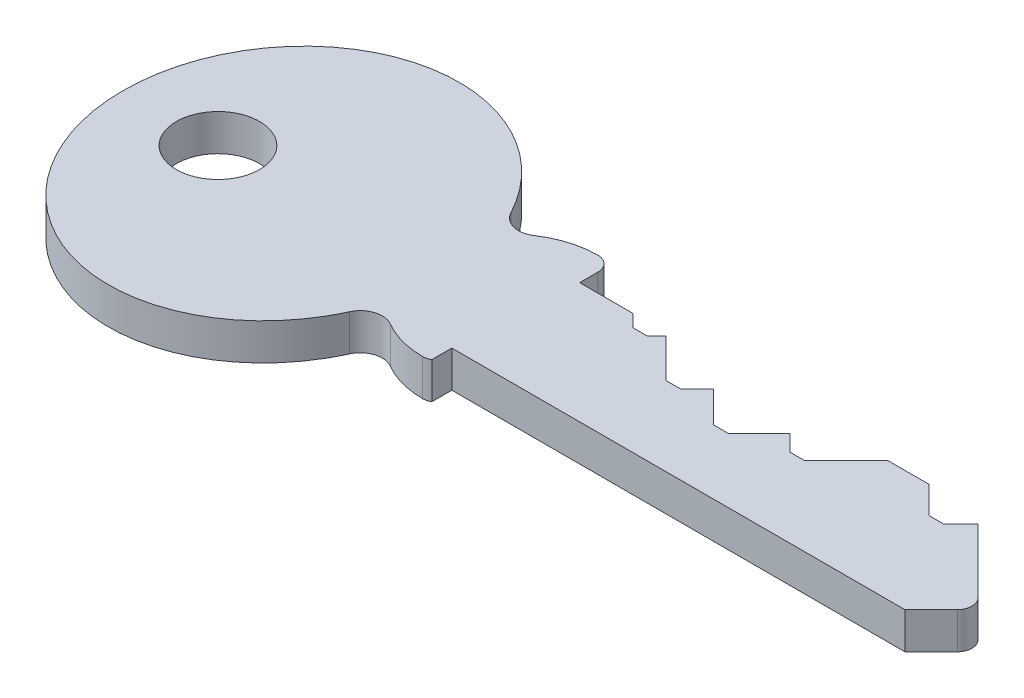
from build123d import *

# Parameters (mm, degrees)
SKETCH1_R          = 2.85
MAIN_BODY_DEPTH    = 1.25
SKETCH8_W          = 0.5
SKETCH8_H          = 2
CUT_EXTRUDE1_DEPTH = 10
CUT_1_DEPTH        = 1.25
CUT_2_DEPTH        = 1.25
CUT_3_DEPTH        = 1.25
CUT_4_DEPTH        = 1.25
CUT_5_DEPTH        = 1.25
CUT_6_DEPTH        = 1.25
FILLET1_R          = 1


with BuildPart() as part:
    # Sketch1 → main body (new, symmetric)
    with BuildSketch(Plane(origin=(0, 0, 0), x_dir=(1, 0, 0), z_dir=(0, 1, 0))):
        with BuildLine():
            Line((0, -4), (30.5, -4))
            Line((30.5, -4), (33, -1.5))
            Line((33, -1.5), (27.25, 4.25))
            Line((27.25, 4.25), (0, 4.25))
            Line((0, 4.25), (0, 5.5))
            ThreePointArc((0, 5.5), (-0.292893219, 6.207106781), (-1, 6.5))
            ThreePointArc((-1, 6.5), (-2.741510774, 6.241701858), (-4.333078548, 5.489046742))
            ThreePointArc((-4.333078548, 5.489046742), (-5.531791754, 5.281505692), (-6.490126472, 6.030892913))
            add(Edge.make_bspline(
                [(-6.490126472, 6.030892913), (-13.210645309, 18.642575993), (-23.258408506, 9.01671215), (-33.306171703, -0.609151693), (-22.710499924, -9.508397103), (-12.114828144, -18.407642513), (-6.153531543, -5.349578253)],
                knots=[2.097370334, 2.097370334, 2.097370334, 3.862218847, 3.862218847, 5.627067361, 5.627067361, 7.391915874, 7.391915874, 7.391915874], degree=2, weights=[1, 0.635280805, 1, 0.635280805, 1, 0.635280805, 1]))
            ThreePointArc((-6.153531543, -5.349578253), (-5.24152664, -4.542405639), (-4.031199832, -4.678013864))
            ThreePointArc((-4.031199832, -4.678013864), (-2.570337036, -5.29085845), (-1, -5.5))
            ThreePointArc((-1, -5.5), (-0.292893219, -5.207106781), (0, -4.5))
            Line((0, -4.5), (0, -4))
        make_face()
        with Locations((-20.5, 0)):
            Circle(SKETCH1_R, mode=Mode.SUBTRACT)
    extrude(amount=MAIN_BODY_DEPTH, both=True)

    # Sketch8 → Cut-Extrude1 (cut)
    with BuildSketch(Plane(origin=(0, 1.25, 0), x_dir=(1, 0, 0), z_dir=(0, 1, 0))):
        with Locations((-0.25, -5)):
            Rectangle(SKETCH8_W, SKETCH8_H)
    extrude(amount=-CUT_EXTRUDE1_DEPTH, mode=Mode.SUBTRACT)


with BuildPart() as body_2:
    # Sketch2 → cut 1 (new, symmetric)
    with BuildSketch(Plane(origin=(0, 0, 0), x_dir=(1, 0, 0), z_dir=(0, 1, 0))):
        Polygon((1, 13.4), (1, 6.9), (4.5, 3.4), (5.5, 3.4), (9, 6.9), (9, 13.4), align=None)
    extrude(amount=CUT_1_DEPTH, both=True)


with BuildPart() as body_3:
    # Sketch3 → cut 2 (new, symmetric)
    with BuildSketch(Plane(origin=(0, 0, 0), x_dir=(1, 0, 0), z_dir=(0, 1, 0))):
        Polygon((5.25, 11.4), (5.25, 4.9), (8.75, 1.4), (9.75, 1.4), (13.25, 4.9), (13.25, 11.4), align=None)
    extrude(amount=CUT_2_DEPTH, both=True)


with BuildPart() as body_4:
    # Sketch4 → cut 3 (new, symmetric)
    with BuildSketch(Plane(origin=(0, 0, 0), x_dir=(1, 0, 0), z_dir=(0, 1, 0))):
        Polygon((9.5, 10.4), (9.5, 3.9), (13, 0.4), (14, 0.4), (17.5, 3.9), (17.5, 10.4), align=None)
    extrude(amount=CUT_3_DEPTH, both=True)


with BuildPart() as body_5:
    # Sketch5 → cut 4 (new, symmetric)
    with BuildSketch(Plane(origin=(0, 0, 0), x_dir=(1, 0, 0), z_dir=(0, 1, 0))):
        Polygon((13.75, 11.4), (13.75, 4.9), (17.25, 1.4), (18.25, 1.4), (21.75, 4.9), (21.75, 11.4), align=None)
    extrude(amount=CUT_4_DEPTH, both=True)


with BuildPart() as body_6:
    # Sketch6 → cut 5 (new, symmetric)
    with BuildSketch(Plane(origin=(0, 0, 0), x_dir=(1, 0, 0), z_dir=(0, 1, 0))):
        Polygon((18, 14.25), (18, 7.75), (21.5, 4.25), (22.5, 4.25), (26, 7.75), (26, 14.25), align=None)
    extrude(amount=CUT_5_DEPTH, both=True)


with BuildPart() as body_7:
    # Sketch7 → cut 6 (new, symmetric)
    with BuildSketch(Plane(origin=(0, 0, 0), x_dir=(1, 0, 0), z_dir=(0, 1, 0))):
        Polygon((22.25, 12.4), (22.25, 5.9), (25.75, 2.4), (26.75, 2.4), (30.25, 5.9), (30.25, 12.4), align=None)
    extrude(amount=CUT_6_DEPTH, both=True)


with BuildPart() as part_1:
    add(part.part)

    # Combine1: cut body 2, body 3, body 4, body 5, body 6, body 7
    add(body_2.part, mode=Mode.SUBTRACT)
    add(body_3.part, mode=Mode.SUBTRACT)
    add(body_4.part, mode=Mode.SUBTRACT)
    add(body_5.part, mode=Mode.SUBTRACT)
    add(body_6.part, mode=Mode.SUBTRACT)
    add(body_7.part, mode=Mode.SUBTRACT)

    # Fillet1
    fillet1_edges = [part_1.edges().sort_by_distance(p)[0] for p in [
        (33, 0, 1.5),
    ]]
    fillet(fillet1_edges, radius=FILLET1_R)


solid = part_1.part
